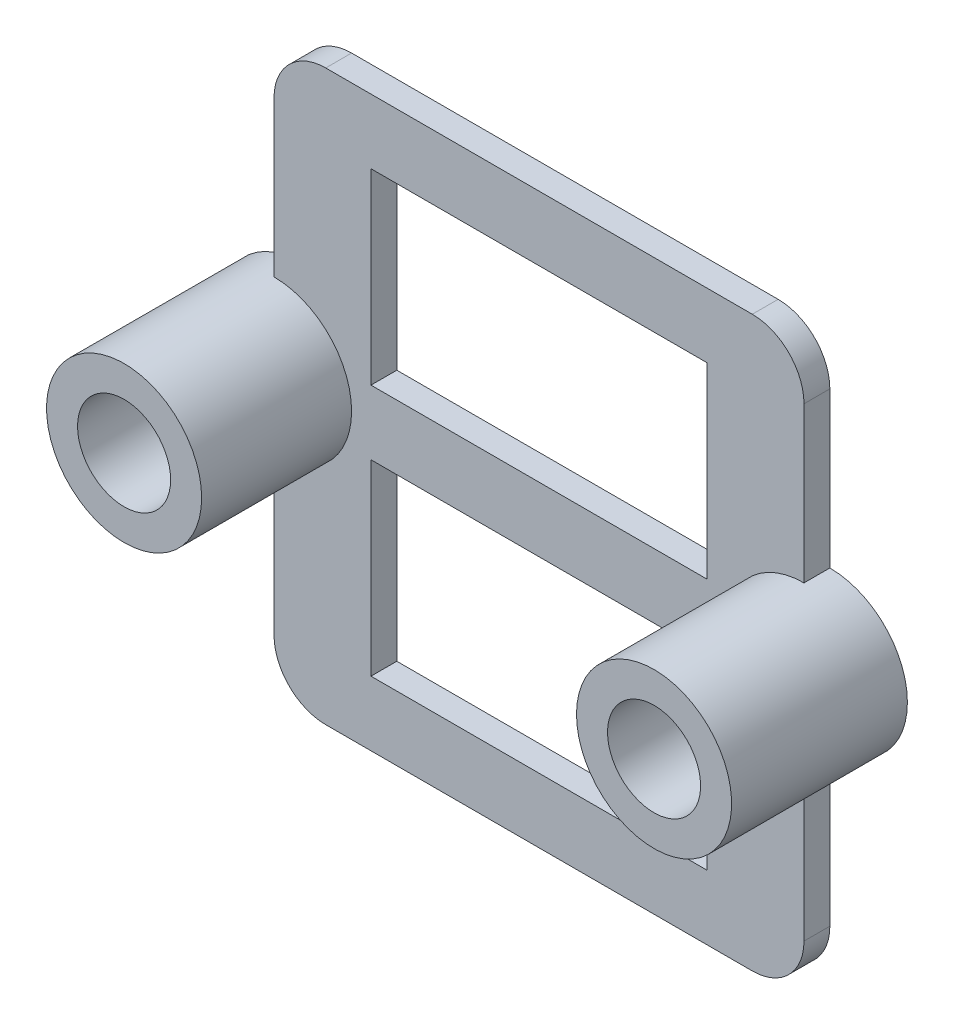
from build123d import *

# Parameters (mm, degrees)
SKETCH1_R           = 1.8
SKETCH1_W           = 13
SKETCH1_H           = 7.25
BOSS_EXTRUDE1_DEPTH = 1
SKETCH2_R           = 3
SKETCH2_R_2         = 1.8
BOSS_EXTRUDE2_DEPTH = 5.8
FILLET4_R           = 2
FILLET5_R           = 2
FILLET6_R           = 2
FILLET7_R           = 2


with BuildPart() as part:
    # Sketch1 → Boss-Extrude1 (new body)
    with BuildSketch(Plane.XY):
        with BuildLine():
            Line((-6.5, 11), (6.5, 11))
            Line((6.5, 11), (10.25, 11))
            Line((10.25, 11), (10.25, 3))
            ThreePointArc((10.25, 3), (13.25, 0), (10.25, -3))
            Line((10.25, -3), (10.25, -11))
            Line((10.25, -11), (6.5, -11))
            Line((6.5, -11), (-6.5, -11))
            Line((-6.5, -11), (-10.25, -11))
            Line((-10.25, -11), (-10.25, -3))
            ThreePointArc((-10.25, -3), (-13.25, 0), (-10.25, 3))
            Line((-10.25, 3), (-10.25, 11))
            Line((-10.25, 11), (-6.5, 11))
        make_face()
        with Locations(Location((-10.25, 0, 0), (0, 0, 180))):
            Circle(SKETCH1_R, mode=Mode.SUBTRACT)
        with Locations((10.25, 0)):
            Circle(SKETCH1_R, mode=Mode.SUBTRACT)
        with Locations((0, -4.875)):
            Rectangle(SKETCH1_W, SKETCH1_H, mode=Mode.SUBTRACT)
        with Locations((0, 4.875)):
            Rectangle(SKETCH1_W, SKETCH1_H, mode=Mode.SUBTRACT)
    extrude(amount=BOSS_EXTRUDE1_DEPTH)

    # Sketch2 → Boss-Extrude2 (add)
    with BuildSketch(Plane.XY.offset(1)):
        with Locations(Location((-10.25, 0, 0), (0, 0, 270))):
            Circle(SKETCH2_R)
        with Locations(Location((-10.25, 0, 0), (0, 0, 180))):
            Circle(SKETCH2_R_2, mode=Mode.SUBTRACT)
        with Locations(Location((10.25, 0, 0), (0, 0, 180))):
            Circle(SKETCH2_R)
        with Locations(Location((10.25, 0, 0), (0, 0, 180))):
            Circle(SKETCH2_R_2, mode=Mode.SUBTRACT)
    extrude(amount=BOSS_EXTRUDE2_DEPTH)

    # Fillet4
    fillet4_edges = [part.edges().sort_by_distance(p)[0] for p in [
        (-10.25, 11, 0.5),
    ]]
    fillet(fillet4_edges, radius=FILLET4_R)

    # Fillet5
    fillet5_edges = [part.edges().sort_by_distance(p)[0] for p in [
        (10.25, 11, 0.5),
    ]]
    fillet(fillet5_edges, radius=FILLET5_R)

    # Fillet6
    fillet6_edges = [part.edges().sort_by_distance(p)[0] for p in [
        (-10.25, -11, 0.5),
    ]]
    fillet(fillet6_edges, radius=FILLET6_R)

    # Fillet7
    fillet7_edges = [part.edges().sort_by_distance(p)[0] for p in [
        (10.25, -11, 0.5),
    ]]
    fillet(fillet7_edges, radius=FILLET7_R)


solid = part.part
